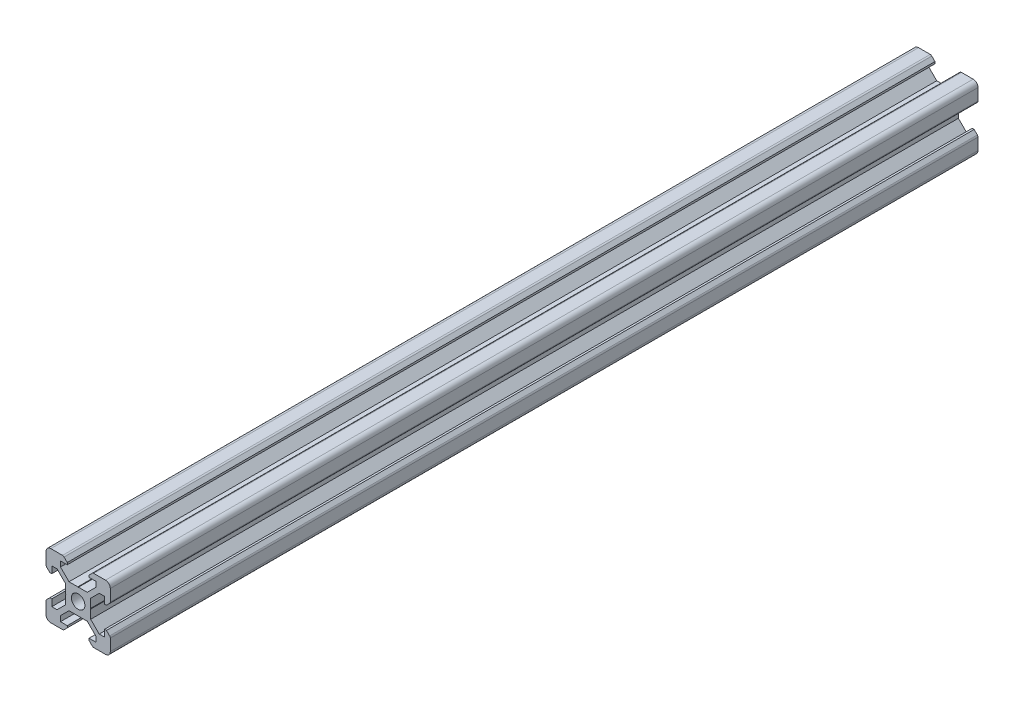
from build123d import *

# Parameters (mm, degrees)
SKETCH1_R           = 2.1
BOSS_EXTRUDE1_DEPTH = 270


with BuildPart() as part:
    # Sketch1 → Boss-Extrude1 (new body)
    with BuildSketch(Plane.XY):
        with BuildLine():
            Line((-8.5, 10), (-4.862792737, 10))
            ThreePointArc((-4.862792737, 10), (-4.598292737, 9.947387679), (-4.374060464, 9.797560464))
            Line((-4.374060464, 9.797560464), (-3.3865, 8.81))
            Line((-3.3865, 8.81), (-3.3865, 8.2))
            Line((-3.3865, 8.2), (-5.5, 8.2))
            Line((-5.5, 8.2), (-5.5, 6.561))
            Line((-5.5, 6.561), (-2.8395, 3.9005))
            Line((-2.8395, 3.9005), (-0.1, 3.9005))
            Line((-0.1, 3.9005), (0, 3.8005))
            Line((0, 3.8005), (0.1, 3.9005))
            Line((0.1, 3.9005), (2.8395, 3.9005))
            Line((2.8395, 3.9005), (5.5, 6.561))
            Line((5.5, 6.561), (5.5, 8.2))
            Line((5.5, 8.2), (3.3865, 8.2))
            Line((3.3865, 8.2), (3.3865, 8.81))
            Line((3.3865, 8.81), (4.374060464, 9.797560464))
            ThreePointArc((4.374060464, 9.797560464), (4.598292737, 9.947387679), (4.862792737, 10))
            Line((4.862792737, 10), (8.5, 10))
            ThreePointArc((8.5, 10), (9.560660172, 9.560660172), (10, 8.5))
            Line((10, 8.5), (10, 4.862792737))
            ThreePointArc((10, 4.862792737), (9.947387679, 4.598292737), (9.797560464, 4.374060464))
            Line((9.797560464, 4.374060464), (8.81, 3.3865))
            Line((8.81, 3.3865), (8.2, 3.3865))
            Line((8.2, 3.3865), (8.2, 5.5))
            Line((8.2, 5.5), (6.561, 5.5))
            Line((6.561, 5.5), (3.9005, 2.8395))
            Line((3.9005, 2.8395), (3.9005, 0.1))
            Line((3.9005, 0.1), (3.8005, 0))
            Line((3.8005, 0), (3.9005, -0.1))
            Line((3.9005, -0.1), (3.9005, -2.8395))
            Line((3.9005, -2.8395), (6.561, -5.5))
            Line((6.561, -5.5), (8.2, -5.5))
            Line((8.2, -5.5), (8.2, -3.3865))
            Line((8.2, -3.3865), (8.81, -3.3865))
            Line((8.81, -3.3865), (9.797560464, -4.374060464))
            ThreePointArc((9.797560464, -4.374060464), (9.947387679, -4.598292737), (10, -4.862792737))
            Line((10, -4.862792737), (10, -8.5))
            ThreePointArc((10, -8.5), (9.560660172, -9.560660172), (8.5, -10))
            Line((8.5, -10), (4.862792737, -10))
            ThreePointArc((4.862792737, -10), (4.598292737, -9.947387679), (4.374060464, -9.797560464))
            Line((4.374060464, -9.797560464), (3.3865, -8.81))
            Line((3.3865, -8.81), (3.3865, -8.2))
            Line((3.3865, -8.2), (5.5, -8.2))
            Line((5.5, -8.2), (5.5, -6.561))
            Line((5.5, -6.561), (2.8395, -3.9005))
            Line((2.8395, -3.9005), (0.1, -3.9005))
            Line((0.1, -3.9005), (0, -3.8005))
            Line((0, -3.8005), (-0.1, -3.9005))
            Line((-0.1, -3.9005), (-2.8395, -3.9005))
            Line((-2.8395, -3.9005), (-5.5, -6.561))
            Line((-5.5, -6.561), (-5.5, -8.2))
            Line((-5.5, -8.2), (-3.3865, -8.2))
            Line((-3.3865, -8.2), (-3.3865, -8.81))
            Line((-3.3865, -8.81), (-4.374060464, -9.797560464))
            ThreePointArc((-4.374060464, -9.797560464), (-4.598292737, -9.947387679), (-4.862792737, -10))
            Line((-4.862792737, -10), (-8.5, -10))
            ThreePointArc((-8.5, -10), (-9.560660172, -9.560660172), (-10, -8.5))
            Line((-10, -8.5), (-10, -4.862792737))
            ThreePointArc((-10, -4.862792737), (-9.947387679, -4.598292737), (-9.797560464, -4.374060464))
            Line((-9.797560464, -4.374060464), (-8.81, -3.3865))
            Line((-8.81, -3.3865), (-8.2, -3.3865))
            Line((-8.2, -3.3865), (-8.2, -5.5))
            Line((-8.2, -5.5), (-6.561, -5.5))
            Line((-6.561, -5.5), (-3.9005, -2.8395))
            Line((-3.9005, -2.8395), (-3.9005, -0.1))
            Line((-3.9005, -0.1), (-3.8005, 0))
            Line((-3.8005, 0), (-3.9005, 0.1))
            Line((-3.9005, 0.1), (-3.9005, 2.8395))
            Line((-3.9005, 2.8395), (-6.561, 5.5))
            Line((-6.561, 5.5), (-8.2, 5.5))
            Line((-8.2, 5.5), (-8.2, 3.3865))
            Line((-8.2, 3.3865), (-8.81, 3.3865))
            Line((-8.81, 3.3865), (-9.797560464, 4.374060464))
            ThreePointArc((-9.797560464, 4.374060464), (-9.947387679, 4.598292737), (-10, 4.862792737))
            Line((-10, 4.862792737), (-10, 8.5))
            ThreePointArc((-10, 8.5), (-9.560660172, 9.560660172), (-8.5, 10))
        make_face()
        Circle(SKETCH1_R, mode=Mode.SUBTRACT)
    extrude(amount=BOSS_EXTRUDE1_DEPTH)


solid = part.part
